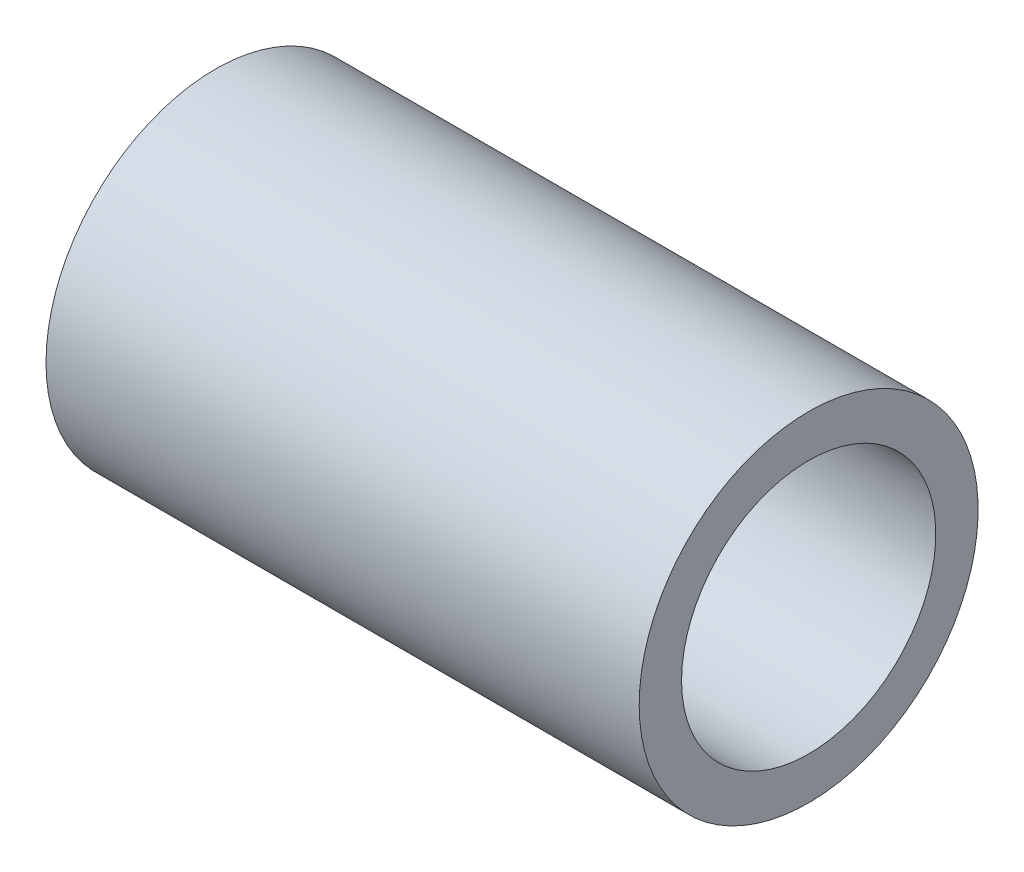
from build123d import *

# Parameters (mm, degrees)
SKETCH1_W = 7
SKETCH1_H = 0.5


with BuildPart() as part:
    # Sketch1 → Revolve1 (revolve)
    with BuildSketch(Plane.XY):
        with Locations((0, 1.75)):
            Rectangle(SKETCH1_W, SKETCH1_H)
    revolve(axis=Axis((-0.962623157, 0, 0), (1, 0, 0)))


solid = part.part
